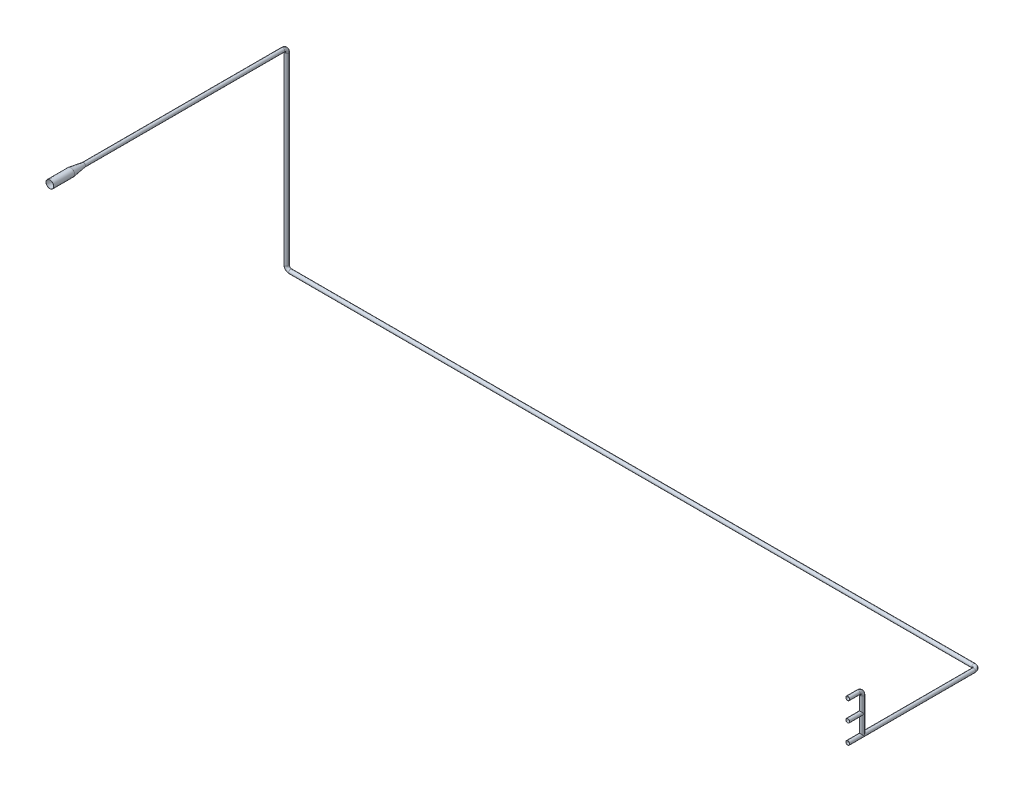
from build123d import *

# Parameters (mm, degrees)
SWEEP_THIN1_PROFILE_R   = 30.000000000000004
SWEEP_THIN1_PROFILE_R_2 = 29.000000000000004
SWEEP_THIN2_PROFILE_R   = 15
SWEEP_THIN2_PROFILE_R_2 = 14
SKETCH109_R             = 14.99999999999705
BOSS_EXTRUDE2_DEPTH     = 101.00000000000001
BOSS_EXTRUDE2_DRAFT     = -8.500000000000018
SWEEP_THIN3_PROFILE_R   = 15
SWEEP_THIN3_PROFILE_R_2 = 14
SWEEP_THIN4_PROFILE_R   = 15
SWEEP_THIN4_PROFILE_R_2 = 14


with BuildPart() as part:
    # Sweep-Thin1: sweep along a curve in space
    with BuildLine() as sweep_thin1_path:
        Line((-34220.21606467534, -16256.702563294808, 41048.148159181685), (-34220.21606467534, -16256.702563294808, 40885.250687197564))
    # Sweep-Thin1 profile (on start of the path) → Sweep-Thin1 (sweep)
    with BuildSketch(Plane(origin=(-34220.21606467534, -16256.702563294808, 41048.148159181685), x_dir=(-1, 0, 0), z_dir=(0, 0, -1))):
        Circle(SWEEP_THIN1_PROFILE_R)
        Circle(SWEEP_THIN1_PROFILE_R_2, mode=Mode.SUBTRACT)
    sweep(path=sweep_thin1_path.line)


with BuildPart() as body_2:
    # Sweep-Thin2: sweep along a curve in space
    with BuildLine() as sweep_thin2_path:
        Line((-34220.21606467534, -16256.702563294808, 40785.250687197564), (-34220.21606467534, -16256.702563294808, 39237.36393186279))
        ThreePointArc((-34220.21606467534, -16286.70256329481, 39207.36393186279), (-34220.21606467534, -16265.489359859213, 39216.150728427194), (-34220.21606467534, -16256.702563294808, 39237.36393186279))
        Line((-34220.21606467534, -16286.70256329481, 39207.36393186279), (-34220.21606467535, -17718.21093222221, 39207.36393186279))
        ThreePointArc((-34190.21606467535, -17748.21093222221, 39207.363931862696), (-34211.429268110944, -17739.424135657806, 39207.36393186276), (-34220.21606467535, -17718.21093222221, 39207.36393186279))
        Line((-34190.21606467535, -17748.21093222221, 39207.363931862696), (-28879.68525767314, -17748.21093222221, 39207.36393186279))
        ThreePointArc((-28849.685257673136, -17748.21093222221, 39237.36393186279), (-28858.47205423754, -17748.21093222221, 39216.150728427194), (-28879.68525767314, -17748.21093222221, 39207.36393186279))
        Line((-28849.685257673136, -17748.21093222221, 39237.36393186279), (-28849.685257673136, -17748.21093222221, 40216.61941081384))
    # Sweep-Thin2 profile (on start of the path) → Sweep-Thin2 (sweep)
    with BuildSketch(Plane(origin=(-34220.21606467534, -16256.702563294808, 40785.250687197564), x_dir=(-1, 0, 0), z_dir=(0, 0, -1))):
        Circle(SWEEP_THIN2_PROFILE_R)
        Circle(SWEEP_THIN2_PROFILE_R_2, mode=Mode.SUBTRACT)
    sweep(path=sweep_thin2_path.line)

    # Sweep-Thin3: sweep along a curve in space
    with BuildLine() as sweep_thin3_path:
        Line((-28849.685257673136, -17748.21093222221, 40105.219711077385), (-28849.685257673136, -17598.21093222222, 40105.219711077385))
        Line((-28849.685257673136, -17598.21093222222, 40105.219711077385), (-28849.685257673136, -17478.210932222228, 40105.219711077385))
        ThreePointArc((-28849.685257673136, -17478.210932222228, 40105.219711077385), (-28849.685257673136, -17456.99772878663, 40114.00650764179), (-28849.685257673136, -17448.210932222228, 40135.219711077385))
        Line((-28849.685257673136, -17448.210932222228, 40135.219711077385), (-28849.685257673136, -17448.210932222228, 40216.61941081384))
    # Sweep-Thin3 profile (on start of the path) → Sweep-Thin3 (sweep)
    with BuildSketch(Plane(origin=(-28849.685257673136, -17748.21093222221, 40105.219711077385), x_dir=(0, 0, 1), z_dir=(0, 1, 0))):
        Circle(SWEEP_THIN3_PROFILE_R)
        Circle(SWEEP_THIN3_PROFILE_R_2, mode=Mode.SUBTRACT)
    sweep(path=sweep_thin3_path.line)

    # Sweep-Thin4: sweep along a curve in space
    with BuildLine() as sweep_thin4_path:
        Line((-28849.685257673136, -17598.21093222222, 40105.219711077385), (-28849.685257673136, -17598.21093222222, 40216.61941081384))
    # Sweep-Thin4 profile (on start of the path) → Sweep-Thin4 (sweep)
    with BuildSketch(Plane(origin=(-28849.685257673136, -17598.21093222222, 40105.219711077385), x_dir=(1, 0, 0), z_dir=(0, 0, 1))):
        Circle(SWEEP_THIN4_PROFILE_R)
        Circle(SWEEP_THIN4_PROFILE_R_2, mode=Mode.SUBTRACT)
    sweep(path=sweep_thin4_path.line)


with BuildPart() as body_3:
    # Sketch109 → Boss-Extrude2 (with draft: the straight prism first)
    with BuildSketch(Plane.XY.offset(40785.250687197564)):
        with Locations((-34220.21606467537, -16256.702563294808)):
            Circle(SKETCH109_R)
    extrude(amount=BOSS_EXTRUDE2_DEPTH)
    # Boss-Extrude2: the draft: its side faces are tilted about the plane it starts from
    boss_extrude2_sides = [body_3.faces().sort_by_distance(p)[0] for p in [
        (-34235.216064675, -16256.702563295, 40835.750687198),
    ]]
    draft(boss_extrude2_sides, Plane.XY.offset(40785.250687197564), BOSS_EXTRUDE2_DRAFT)


solid = Compound([part.part, body_2.part, body_3.part])
